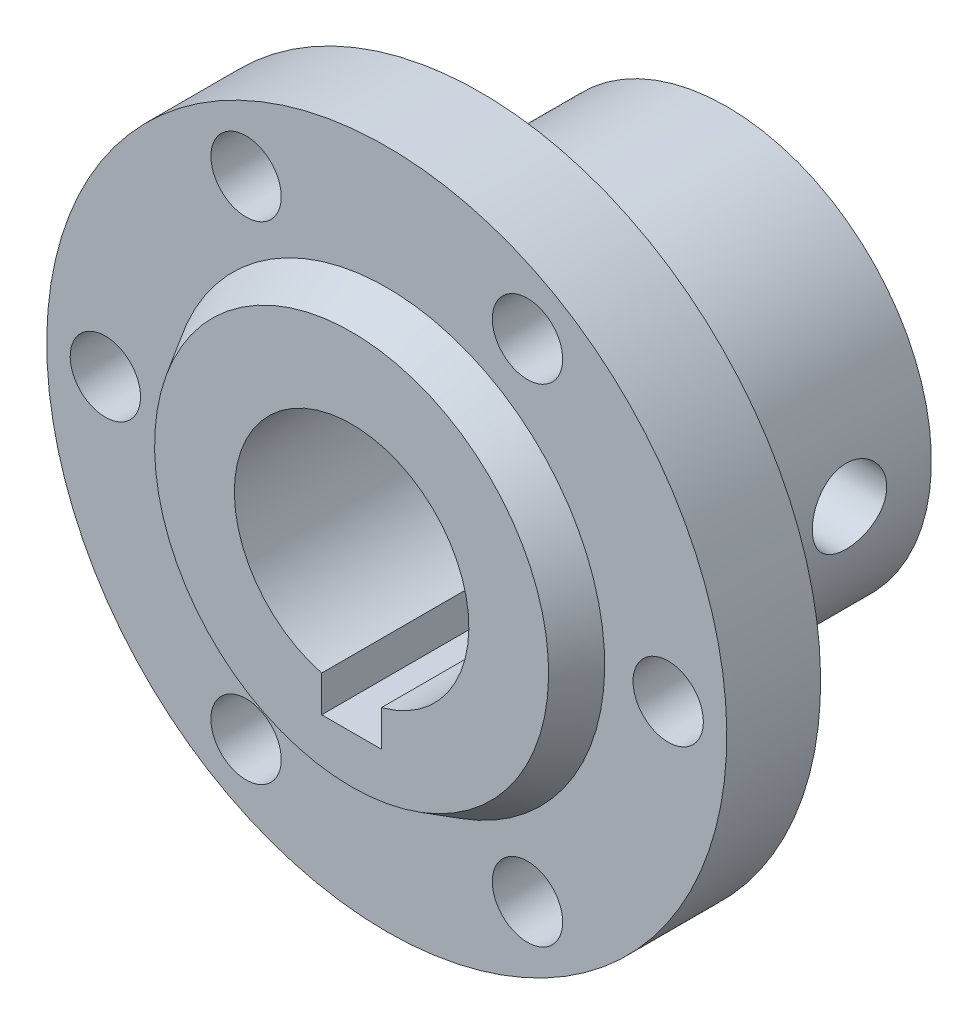
from build123d import *

# Parameters (mm, degrees)
CUT_EXTRUDE1_DEPTH      = 12
CUT_EXTRUDE1_DEPTH_BACK = 22
SKETCH3_R               = 3
CUT_EXTRUDE2_DEPTH      = 22
CUT_EXTRUDE2_DEPTH_BACK = 12
SKETCH4_R               = 3.175
CUT_EXTRUDE3_DEPTH      = 30
CUT_EXTRUDE3_DEPTH_BACK = 30


with BuildPart() as part:
    # Sketch1 → Revolve1 (revolve)
    with BuildSketch(Plane(origin=(0, 0, 0), x_dir=(0, 0, -1), z_dir=(1, 0, 0))):
        Polygon((21, 17.45), (7.03, 17.45), (7.03, 18.5), (0, 18.5), (0, 29), (-8, 29), (-8, 18.586235054), (-11, 16.803216346), (-11, 10), (21, 10), align=None)
    revolve(axis=Axis((0, 0, 11), (0, 0, -1)))

    # Sketch2 → Cut-Extrude1 (cut, two sides)
    with BuildSketch(Plane.XY) as cut_extrude1_sk:
        with BuildLine():
            Line((-2.55, -12.75), (2.55, -12.75))
            Line((2.55, -12.75), (2.55, -9.66941053))
            ThreePointArc((2.55, -9.66941053), (0, -10), (-2.55, -9.66941053))
            Line((-2.55, -9.66941053), (-2.55, -12.75))
        make_face()
    extrude(amount=CUT_EXTRUDE1_DEPTH, mode=Mode.SUBTRACT)
    extrude(cut_extrude1_sk.sketch, amount=-CUT_EXTRUDE1_DEPTH_BACK, mode=Mode.SUBTRACT)

    # Sketch3 → Cut-Extrude2 (cut, two sides)
    with BuildSketch(Plane(origin=(0, 0, 0), x_dir=(-1, 0, 0), z_dir=(0, 0, -1))) as cut_extrude2_sk:
        with Locations((-24, 0)):
            Circle(SKETCH3_R)
        with Locations((-12, 20.784609691)):
            Circle(SKETCH3_R)
        with Locations((12, 20.784609691)):
            Circle(SKETCH3_R)
        with Locations((24, 0)):
            Circle(SKETCH3_R)
        with Locations((12, -20.784609691)):
            Circle(SKETCH3_R)
        with Locations((-12, -20.784609691)):
            Circle(SKETCH3_R)
    extrude(amount=CUT_EXTRUDE2_DEPTH, mode=Mode.SUBTRACT)
    extrude(cut_extrude2_sk.sketch, amount=-CUT_EXTRUDE2_DEPTH_BACK, mode=Mode.SUBTRACT)

    # Sketch4 → Cut-Extrude3 (cut, two sides)
    with BuildSketch(Plane(origin=(0, 0, 0), x_dir=(0, -1, 0), z_dir=(1, 0, 0))) as cut_extrude3_sk:
        with Locations((0, 14.015)):
            Circle(SKETCH4_R)
    extrude(amount=CUT_EXTRUDE3_DEPTH, mode=Mode.SUBTRACT)
    extrude(cut_extrude3_sk.sketch, amount=-CUT_EXTRUDE3_DEPTH_BACK, mode=Mode.SUBTRACT)


solid = part.part
